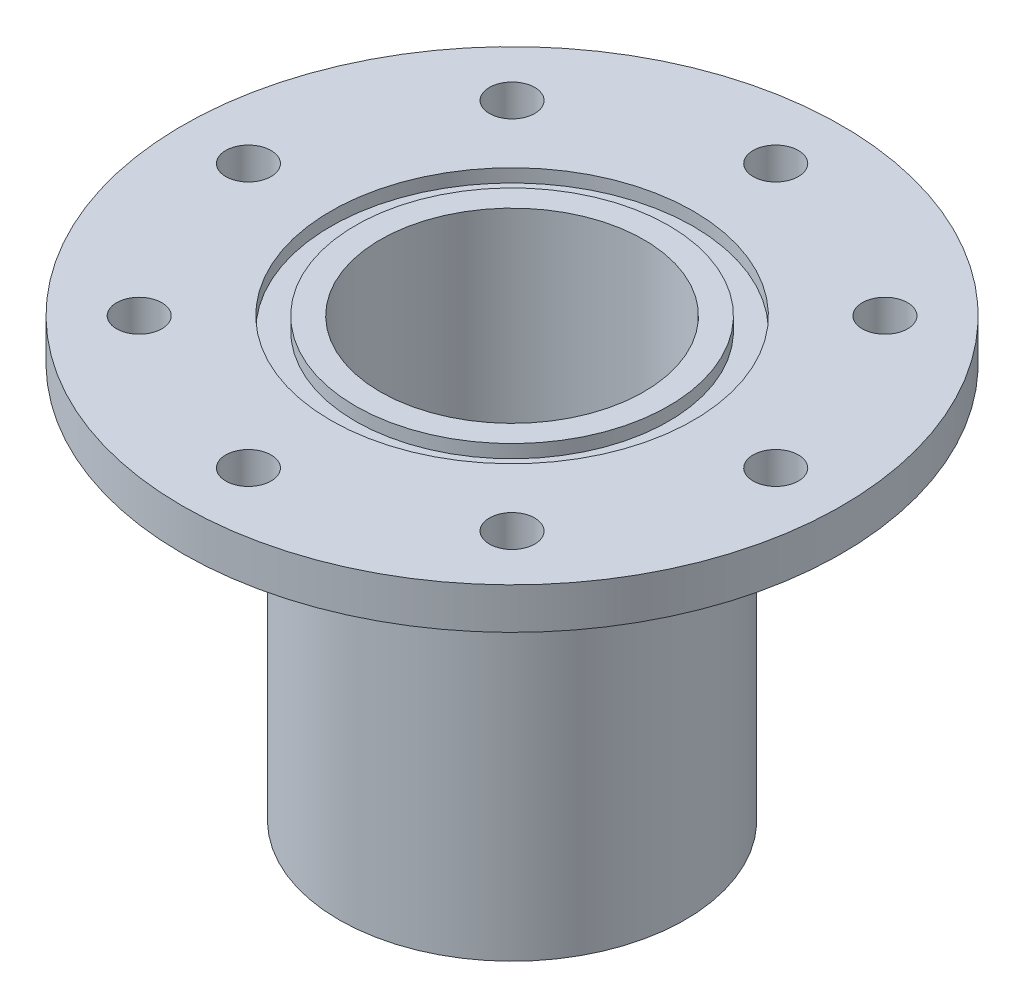
from build123d import *

# Parameters (mm, degrees)
FILLET1_R                       = 10.16
F_11_16_0_6875_DIAMETER_HOLE1_D = 17.4625
CIRPATTERN1_COUNT               = 8


with BuildPart() as part:
    # Sketch1 → Revolve1 (revolve)
    with BuildSketch(Plane.XY):
        Polygon((50.8, -152.4), (66.675, -152.4), (66.675, 0), (127, 0), (127, 15.875), (69.85, 15.875), (69.85, 10.795), (60.325, 10.795), (60.325, 15.875), (50.8, 15.875), align=None)
    revolve(axis=Axis((0, 66.332099957, 0), (0, -1, 0)))

    # Fillet1
    fillet1_edges = [part.edges().sort_by_distance(p)[0] for p in [
        (-66.675, 0, 0),
    ]]
    fillet(fillet1_edges, radius=FILLET1_R)

    # 11_16 _0.6875_ Diameter Hole1 (through all)
    with Locations(Plane(origin=(0, 15.875, 0), x_dir=(-1, 0, 0), z_dir=(0, 1, 0))):
        with Locations((0, -101.6)):
            f_11_16_0_6875_diameter_hole1 = Hole(F_11_16_0_6875_DIAMETER_HOLE1_D / 2)

    # CirPattern1: 11_16 _0.6875_ Diameter Hole1 ×8 about axis
    cirpattern1_axis = Axis((0, -152.4, 0), (0, 1, 0))
    for i in range(1, CIRPATTERN1_COUNT):
        add(f_11_16_0_6875_diameter_hole1.rotate(cirpattern1_axis, i * 360 / CIRPATTERN1_COUNT), mode=Mode.SUBTRACT)


solid = part.part
